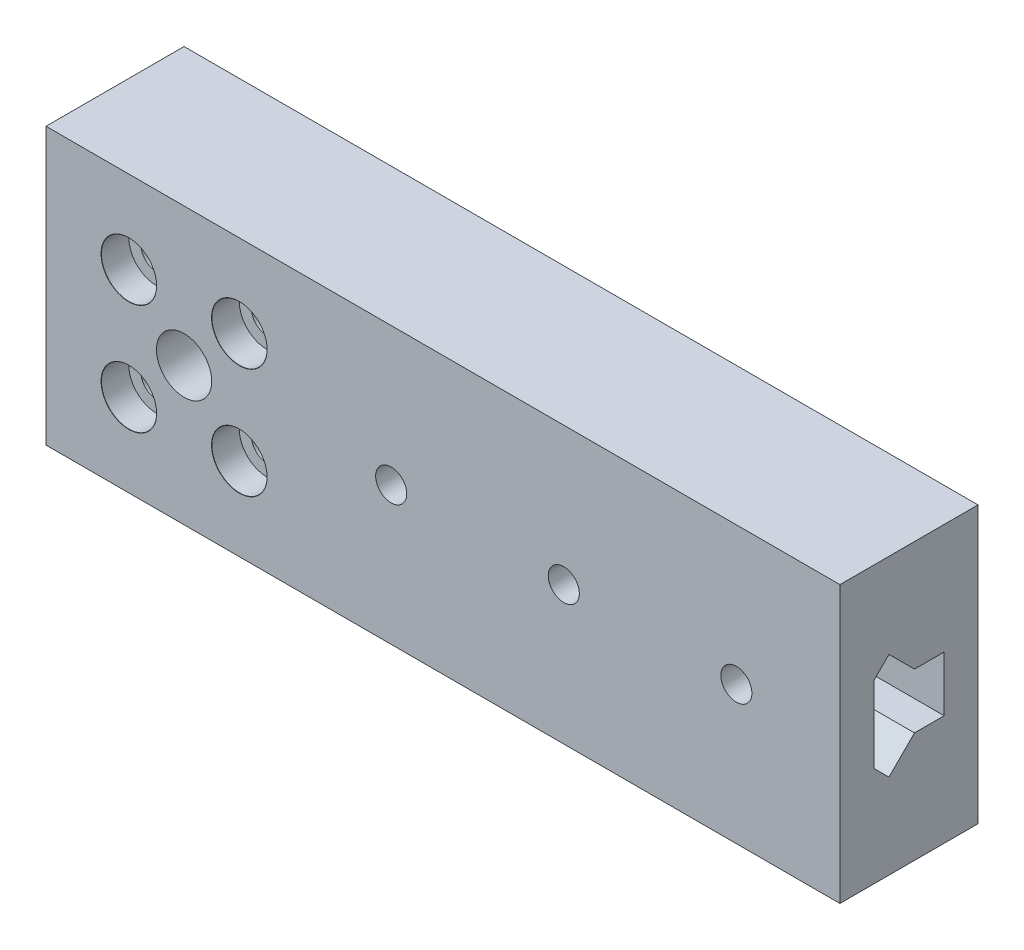
from build123d import *

# Parameters (mm, degrees)
SKETCH1_W                     = 115
SKETCH1_H                     = 40
SKETCH1_R                     = 4
BOSS_EXTRUDE1_DEPTH           = 10
CBORE_FOR_M4_SHCS1_AT_2_COUNT = 2
CBORE_FOR_M4_SHCS1_AT_2_PITCH = 16
CBORE_FOR_M4_SHCS1_AT_3_COUNT = 2
CBORE_FOR_M4_SHCS1_AT_3_PITCH = 16
CBORE_FOR_M4_SHCS1_AT_4_COUNT = 2
CBORE_FOR_M4_SHCS1_AT_4_PITCH = 22.627416998
SKETCH5_R                     = 16.5
SKETCH5_R_2                   = 4
CUT_EXTRUDE1_DEPTH            = 12
CUT_EXTRUDE2_DEPTH            = 75
M4_CLEARANCE_HOLE1_D          = 4.5


with BuildPart() as part:
    # Sketch1 → Boss-Extrude1 (new body, symmetric)
    with BuildSketch(Plane.XY):
        with Locations((17.5, 0)):
            Rectangle(SKETCH1_W, SKETCH1_H)
        with Locations((-20, 0)):
            Circle(SKETCH1_R, mode=Mode.SUBTRACT)
    extrude(amount=BOSS_EXTRUDE1_DEPTH, both=True)

    # Sketch3 → CBORE for M4 SHCS1 (revolve, cut)
    with BuildSketch(Plane(origin=(-28, 8, 10), x_dir=(0, -1, 0), z_dir=(1, 0, 0))):
        Polygon((0, 0), (0, 20), (2.25, 20), (2.25, 4), (4, 4), (4, 0.025), (4.025, 0), align=None)
    cbore_for_m4_shcs1 = revolve(axis=Axis((-28, 8, 16.35), (0, 0, -1)), mode=Mode.SUBTRACT)

    # CBORE for M4 SHCS1 at 2: CBORE for M4 SHCS1 ×2
    with Locations(*[(i * CBORE_FOR_M4_SHCS1_AT_2_PITCH, 0, 0) for i in range(1, CBORE_FOR_M4_SHCS1_AT_2_COUNT)]):
        add(cbore_for_m4_shcs1, mode=Mode.SUBTRACT)

    # CBORE for M4 SHCS1 at 3: CBORE for M4 SHCS1 ×2
    with Locations(*[(0, -i * CBORE_FOR_M4_SHCS1_AT_3_PITCH, 0) for i in range(1, CBORE_FOR_M4_SHCS1_AT_3_COUNT)]):
        add(cbore_for_m4_shcs1, mode=Mode.SUBTRACT)

    # CBORE for M4 SHCS1 at 4: CBORE for M4 SHCS1 ×2
    with Locations(*[Vector(0.707106781, -0.707106781, 0) * (i * CBORE_FOR_M4_SHCS1_AT_4_PITCH) for i in range(1, CBORE_FOR_M4_SHCS1_AT_4_COUNT)]):
        add(cbore_for_m4_shcs1, mode=Mode.SUBTRACT)

    # Sketch5 → Cut-Extrude1 (cut)
    with BuildSketch(Plane(origin=(0, 0, -10), x_dir=(-1, 0, 0), z_dir=(0, 0, -1))):
        with Locations((20, 0)):
            Circle(SKETCH5_R)
        with Locations((20, 0)):
            Circle(SKETCH5_R_2, mode=Mode.SUBTRACT)
    extrude(amount=-CUT_EXTRUDE1_DEPTH, mode=Mode.SUBTRACT)

    # Sketch6 → Cut-Extrude2 (cut)
    with BuildSketch(Plane(origin=(75, 0, 0), x_dir=(0, 0, -1), z_dir=(1, 0, 0))):
        Polygon((-5.1, 5.5), (-2.9, 7.7), (0.8, 4), (5.1, 4), (5.1, 0), (-5.1, 0), align=None)
    cut_extrude2 = extrude(amount=-CUT_EXTRUDE2_DEPTH, mode=Mode.SUBTRACT)

    # Mirror1: Cut-Extrude2 across plane
    add(cut_extrude2.mirror(Plane(origin=(-12.780062598, 0, 5.1), x_dir=(0, 0, 1), z_dir=(0, -1, 0))), mode=Mode.SUBTRACT)

    # M4 Clearance Hole1 (through all)
    with Locations(Plane(origin=(0, 0, -10), x_dir=(-1, 0, 0), z_dir=(0, 0, -1))):
        with Locations((-10, 0), (-35, 0), (-60, 0)):
            Hole(M4_CLEARANCE_HOLE1_D / 2)


solid = part.part
